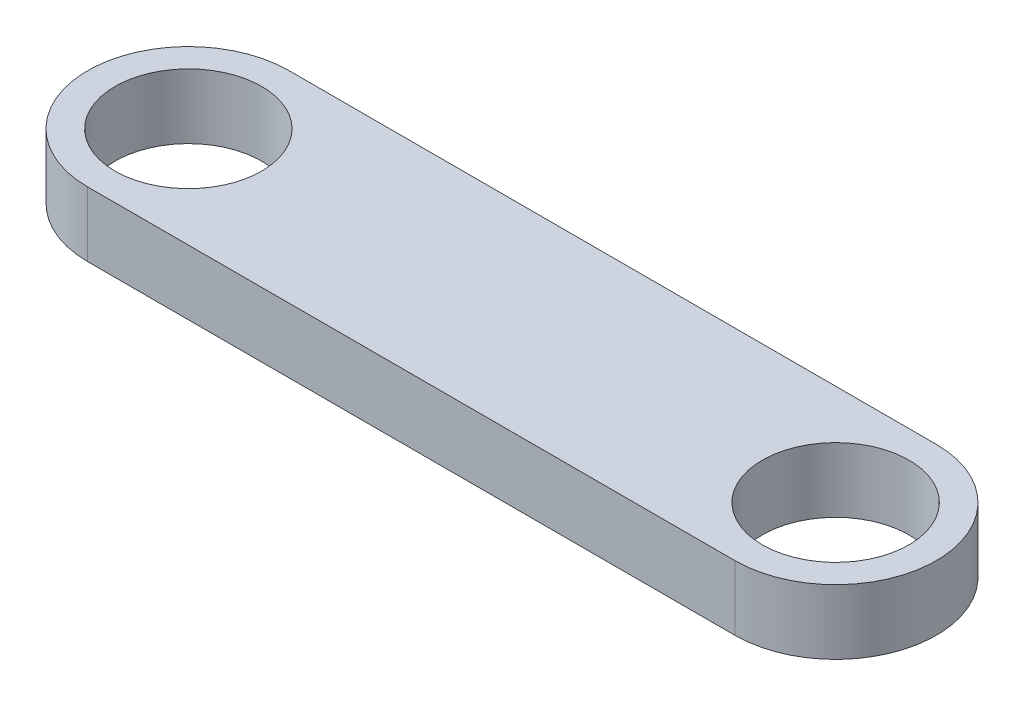
from build123d import *

# Parameters (mm, degrees)
BOSS_EXTRUDE1_DEPTH = 4.5


with BuildPart() as part:
    # Sketch1 → Boss-Extrude1 (new body)
    with BuildSketch(Plane(origin=(0, 0, 0), x_dir=(1, 0, 0), z_dir=(0, 1, 0))):
        with BuildLine():
            ThreePointArc((-22.5, 7), (-29.5, 0), (-22.5, -7))
            Line((-22.5, -7), (-22.5, -5.1))
            ThreePointArc((-22.5, -5.1), (-27.6, 0), (-22.5, 5.1))
            Line((-22.5, 5.1), (-22.5, 7))
        make_face()
        with BuildLine():
            Line((-22.5, -5.1), (-22.5, -7))
            ThreePointArc((-22.5, -7), (-17.550252532, -4.949747468), (-15.5, 0))
            ThreePointArc((-15.5, 0), (-17.550252532, 4.949747468), (-22.5, 7))
            Line((-22.5, 7), (-22.5, 5.1))
            ThreePointArc((-22.5, 5.1), (-18.893755416, 3.606244584), (-17.4, 0))
            ThreePointArc((-17.4, 0), (-18.893755416, -3.606244584), (-22.5, -5.1))
        make_face()
        with BuildLine():
            ThreePointArc((-22.5, 7), (-29.5, 0), (-22.5, -7))
            Line((-22.5, -7), (-22.5, -5.1))
            ThreePointArc((-22.5, -5.1), (-27.6, 0), (-22.5, 5.1))
            Line((-22.5, 5.1), (-22.5, 7))
        make_face()
        with BuildLine():
            Line((-22.5, -5.1), (-22.5, -7))
            ThreePointArc((-22.5, -7), (-17.550252532, -4.949747468), (-15.5, 0))
            ThreePointArc((-15.5, 0), (-17.550252532, 4.949747468), (-22.5, 7))
            Line((-22.5, 7), (-22.5, 5.1))
            ThreePointArc((-22.5, 5.1), (-18.893755416, 3.606244584), (-17.4, 0))
            ThreePointArc((-17.4, 0), (-18.893755416, -3.606244584), (-22.5, -5.1))
        make_face()
        with BuildLine():
            ThreePointArc((-15.5, 0), (-17.550252532, -4.949747468), (-22.5, -7))
            Line((-22.5, -7), (22.5, -7))
            ThreePointArc((22.5, -7), (15.5, 0), (22.5, 7))
            Line((22.5, 7), (-22.5, 7))
            ThreePointArc((-22.5, 7), (-17.550252532, 4.949747468), (-15.5, 0))
        make_face()
        with BuildLine():
            ThreePointArc((22.5, 7), (15.5, 0), (22.5, -7))
            Line((22.5, -7), (22.5, -5.1))
            ThreePointArc((22.5, -5.1), (17.4, 0), (22.5, 5.1))
            Line((22.5, 5.1), (22.5, 7))
        make_face()
        with BuildLine():
            Line((22.5, -5.1), (22.5, -7))
            ThreePointArc((22.5, -7), (27.449747468, -4.949747468), (29.5, 0))
            ThreePointArc((29.5, 0), (27.449747468, 4.949747468), (22.5, 7))
            Line((22.5, 7), (22.5, 5.1))
            ThreePointArc((22.5, 5.1), (26.106244584, 3.606244584), (27.6, 0))
            ThreePointArc((27.6, 0), (26.106244584, -3.606244584), (22.5, -5.1))
        make_face()
        with BuildLine():
            ThreePointArc((22.5, 7), (15.5, 0), (22.5, -7))
            Line((22.5, -7), (22.5, -5.1))
            ThreePointArc((22.5, -5.1), (17.4, 0), (22.5, 5.1))
            Line((22.5, 5.1), (22.5, 7))
        make_face()
        with BuildLine():
            Line((22.5, -5.1), (22.5, -7))
            ThreePointArc((22.5, -7), (27.449747468, -4.949747468), (29.5, 0))
            ThreePointArc((29.5, 0), (27.449747468, 4.949747468), (22.5, 7))
            Line((22.5, 7), (22.5, 5.1))
            ThreePointArc((22.5, 5.1), (26.106244584, 3.606244584), (27.6, 0))
            ThreePointArc((27.6, 0), (26.106244584, -3.606244584), (22.5, -5.1))
        make_face()
    extrude(amount=BOSS_EXTRUDE1_DEPTH)


solid = part.part
